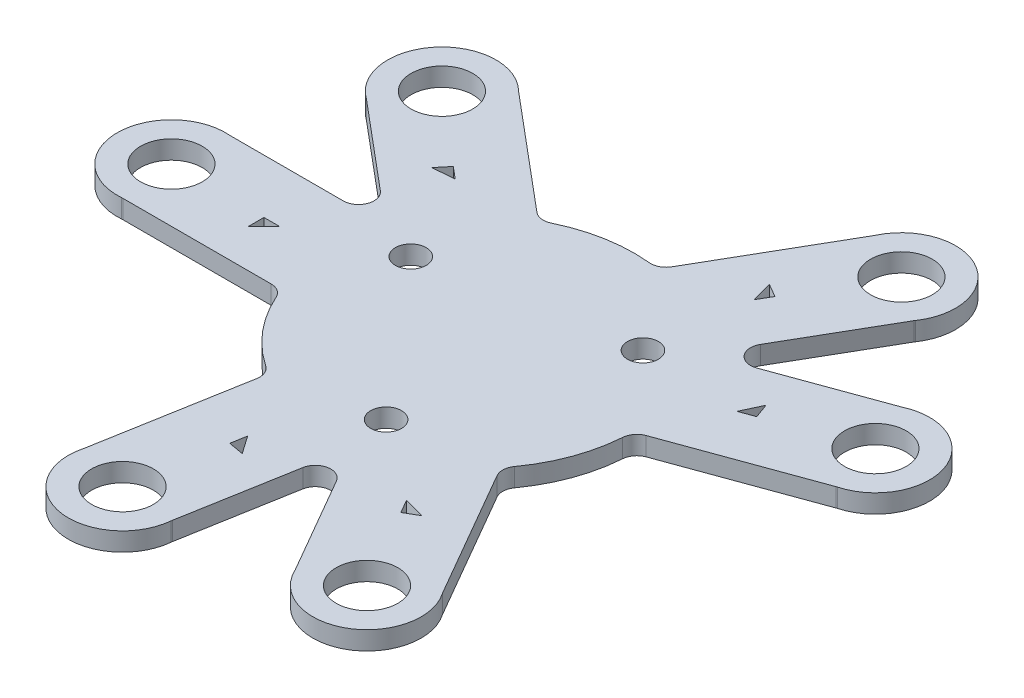
from build123d import *

# Parameters (mm, degrees)
SKETCH1_R           = 2
SKETCH1_R_2         = 1
BOSS_EXTRUDE1_DEPTH = 1.2
FILLET1_R           = 1


with BuildPart() as part:
    # Sketch1 → Boss-Extrude1 (new body)
    with BuildSketch(Plane(origin=(0, 0, 0), x_dir=(1, 0, 0), z_dir=(0, 1, 0))):
        with BuildLine():
            ThreePointArc((-19.691368668, 3.5), (-23.513581264, 0), (-19.691368668, -3.5))
            Line((-19.691368668, -3.5), (-9.367496998, -3.5))
            ThreePointArc((-9.367496998, -3.5), (-7.660444431, -6.427876097), (-5.073475918, -8.617415048))
            Line((-5.073475918, -8.617415048), (-6.86619742, -18.784443909))
            ThreePointArc((-6.86619742, -18.784443909), (-4.083090537, -23.15635713), (0.027456851, -19.999981153))
            Line((0.027456851, -19.999981153), (1.776996571, -10.077848346))
            Line((1.776996571, -10.077848346), (6.814595421, -18.803225501))
            ThreePointArc((6.814595421, -18.803225501), (11.756790632, -20.363358709), (12.876773247, -15.303225501))
            Line((12.876773247, -15.303225501), (7.714837412, -6.36249037))
            ThreePointArc((7.714837412, -6.36249037), (9.396926208, -3.420201433), (9.999638306, -0.085051507))
            Line((9.999638306, -0.085051507), (19.700904332, 3.445920561))
            ThreePointArc((19.700904332, 3.445920561), (22.095538802, 8.042118434), (17.306763328, 10.023768907))
            Line((17.306763328, 10.023768907), (7.839174397, 6.577848346))
            Line((7.839174397, 6.577848346), (12.876773247, 15.303225501))
            ThreePointArc((12.876773247, 15.303225501), (11.756790632, 20.363358709), (6.814595421, 18.803225501))
            Line((6.814595421, 18.803225501), (1.652659586, 9.86249037))
            ThreePointArc((1.652659586, 9.86249037), (-1.736481777, 9.84807753), (-4.926162387, 8.702466555))
            Line((-4.926162387, 8.702466555), (-12.834706911, 15.338523348))
            ThreePointArc((-12.834706911, 15.338523348), (-18.012448265, 15.114238696), (-17.334220179, 9.976212246))
            Line((-17.334220179, 9.976212246), (-9.616170968, 3.5))
            Line((-9.616170968, 3.5), (-19.691368668, 3.5))
        make_face()
        with Locations((-20, 0)):
            Circle(SKETCH1_R, mode=Mode.SUBTRACT)
        Polygon((-14, -1), (-14, 0), (-13, 0), align=None, mode=Mode.SUBTRACT)
        with Locations((5.745333323, 4.820907073)):
            Circle(SKETCH1_R_2, mode=Mode.SUBTRACT)
        with Locations((1.302361333, -7.386058148)):
            Circle(SKETCH1_R_2, mode=Mode.SUBTRACT)
        with Locations((-7.047694656, 2.565151075)):
            Circle(SKETCH1_R_2, mode=Mode.SUBTRACT)
        Polygon((-2.25742631, -12.802500789), (-1.446266734, -13.96095672), (-2.431074487, -13.787308542), align=None, mode=Mode.SUBTRACT)
        with Locations((-3.472963553, -19.69615506)):
            Circle(SKETCH1_R, mode=Mode.SUBTRACT)
        with Locations((-15.320888862, 12.855752194)):
            Circle(SKETCH1_R, mode=Mode.SUBTRACT)
        Polygon((-10.724622204, 8.999026536), (-9.958577761, 8.356238926), (-11.367409813, 8.232982092), align=None, mode=Mode.SUBTRACT)
        Polygon((7, -12.124355653), (6.5, -11.258330249), (7.866025404, -11.624355653), align=None, mode=Mode.SUBTRACT)
        with Locations((10, -17.320508076)):
            Circle(SKETCH1_R, mode=Mode.SUBTRACT)
        with Locations((10, 17.320508076)):
            Circle(SKETCH1_R, mode=Mode.SUBTRACT)
        Polygon((6.133974596, 12.624355653), (7, 12.124355653), (6.5, 11.258330249), align=None, mode=Mode.SUBTRACT)
        with Locations((18.793852416, 6.840402867)):
            Circle(SKETCH1_R, mode=Mode.SUBTRACT)
        Polygon((13.155696691, 4.788282007), (12.21600407, 4.446261863), (12.813676548, 5.727974627), align=None, mode=Mode.SUBTRACT)
    extrude(amount=BOSS_EXTRUDE1_DEPTH)

    # Fillet1
    fillet1_edges = [part.edges().sort_by_distance(p)[0] for p in [
        (17.306763328, 0.6, -10.023768907),
        (19.700904332, 0.6, -3.445920561),
        (9.999638306, 0.6, 0.085051507),
        (7.714837412, 0.6, 6.36249037),
        (12.876773247, 0.6, 15.303225501),
        (6.814595421, 0.6, 18.803225501),
        (1.776996571, 0.6, 10.077848346),
        (0.027456851, 0.6, 19.999981153),
        (-6.86619742, 0.6, 18.784443909),
        (-5.073475918, 0.6, 8.617415048),
        (-9.367496998, 0.6, 3.5),
        (-19.691368668, 0.6, 3.5),
        (-19.691368668, 0.6, -3.5),
        (-9.616170968, 0.6, -3.5),
        (-17.334220179, 0.6, -9.976212246),
        (-12.834706911, 0.6, -15.338523348),
        (-4.926162387, 0.6, -8.702466555),
        (1.652659586, 0.6, -9.86249037),
        (6.814595421, 0.6, -18.803225501),
        (12.876773247, 0.6, -15.303225501),
        (7.839174397, 0.6, -6.577848346),
    ]]
    fillet(fillet1_edges, radius=FILLET1_R)


solid = part.part
